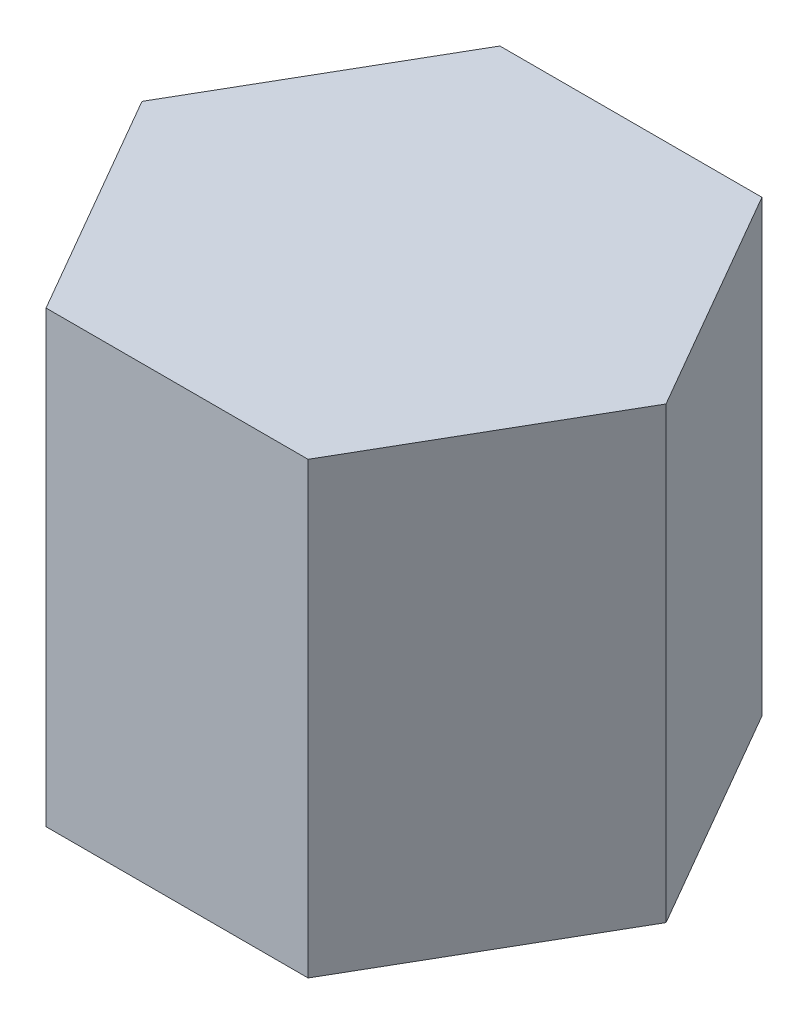
from build123d import *

# Parameters (mm, degrees)
BOSS_EXTRUDE1_DEPTH = 152.4


with BuildPart() as part:
    # Sketch1 → Boss-Extrude1 (new body)
    with BuildSketch(Plane(origin=(0, 0, 0), x_dir=(1, 0, 0), z_dir=(0, 1, 0))):
        Polygon((88.9, 0), (44.45, 76.989658396), (-44.45, 76.989658396), (-88.9, 0), (-44.45, -76.989658396), (44.45, -76.989658396), align=None)
    extrude(amount=BOSS_EXTRUDE1_DEPTH)


solid = part.part
